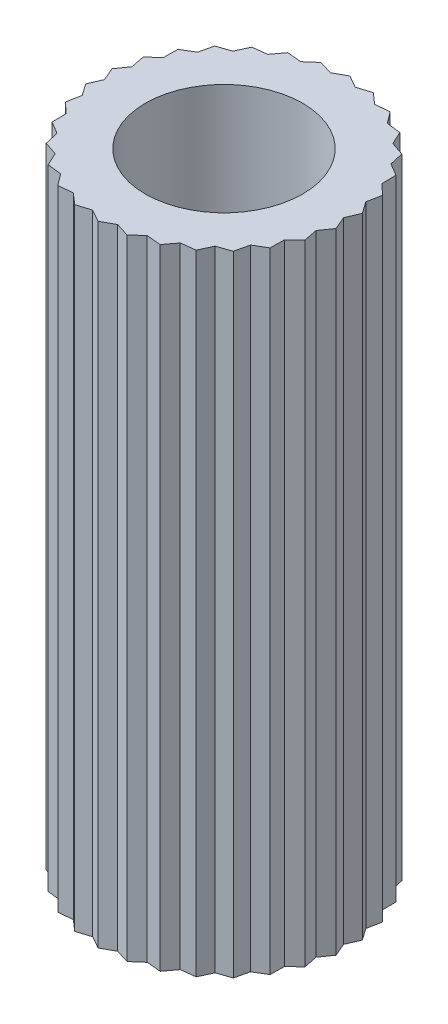
from build123d import *

# Parameters (mm, degrees)
SKETCH_1_R      = 1
EXTRUDE_1_DEPTH = 8


with BuildPart() as part:
    # 草图1 → 凸台-拉伸1 (new body)
    with BuildSketch(Plane(origin=(0, 0, 0), x_dir=(1, 0, 0), z_dir=(0, 1, 0))):
        Polygon((0, 1.6), (-0.158843146, 1.511291584), (-0.332658705, 1.565036161), (-0.469587231, 1.44524089), (-0.650778629, 1.461672732), (-0.7598081, 1.316026234), (-0.940456404, 1.294427191), (-1.01682171, 1.129294916), (-1.189031721, 1.07060897), (-1.229395331, 0.893207992), (-1.385640646, 0.8), (-1.388238477, 0.618083592), (-1.521690426, 0.494427191), (-1.486408941, 0.315945974), (-1.591235033, 0.167245541), (-1.519616201, 0), (-1.591235033, -0.167245541), (-1.486408941, -0.315945974), (-1.521690426, -0.494427191), (-1.388238477, -0.618083592), (-1.385640646, -0.8), (-1.229395331, -0.893207992), (-1.189031721, -1.07060897), (-1.01682171, -1.129294916), (-0.940456404, -1.294427191), (-0.7598081, -1.316026234), (-0.650778629, -1.461672732), (-0.469587231, -1.44524089), (-0.332658705, -1.565036161), (-0.158843146, -1.511291584), (0, -1.6), (0.158843146, -1.511291584), (0.332658705, -1.565036161), (0.469587231, -1.44524089), (0.650778629, -1.461672732), (0.7598081, -1.316026234), (0.940456404, -1.294427191), (1.01682171, -1.129294916), (1.189031721, -1.07060897), (1.229395331, -0.893207992), (1.385640646, -0.8), (1.388238477, -0.618083592), (1.521690426, -0.494427191), (1.486408941, -0.315945974), (1.591235033, -0.167245541), (1.519616201, 0), (1.591235033, 0.167245541), (1.486408941, 0.315945974), (1.521690426, 0.494427191), (1.388238477, 0.618083592), (1.385640646, 0.8), (1.229395331, 0.893207992), (1.189031721, 1.07060897), (1.01682171, 1.129294916), (0.940456404, 1.294427191), (0.7598081, 1.316026234), (0.650778629, 1.461672732), (0.469587231, 1.44524089), (0.332658705, 1.565036161), (0.158843146, 1.511291584), align=None)
        Circle(SKETCH_1_R, mode=Mode.SUBTRACT)
    extrude(amount=EXTRUDE_1_DEPTH)


solid = part.part
